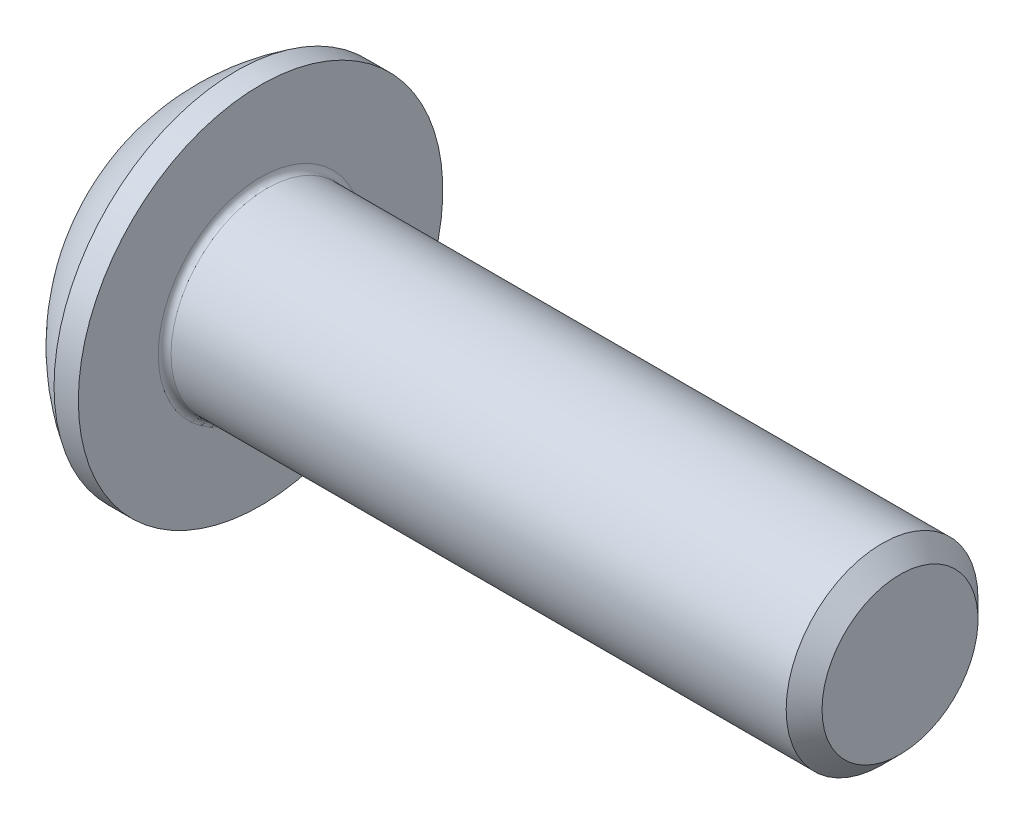
from build123d import *

# Parameters (mm, degrees)
FILLET1_R   = 0.1
HEX_2_DEPTH = 1.04


with BuildPart() as part:
    # BodySke → BaseBody (revolve)
    with BuildSketch(Plane.XY):
        with BuildLine():
            Line((11.65, 0), (11.65, 1.2195))
            Line((11.65, 1.2195), (11.3695, 1.5))
            Line((11.3695, 1.5), (1.65, 1.5))
            Line((1.65, 1.5), (1.65, 2.85))
            Line((1.65, 2.85), (1.27, 2.85))
            ThreePointArc((1.27, 2.85), (0.53140404, 2.229827628), (0, 1.425))
            Line((0, 1.425), (0, 0))
            Line((0, 0), (11.65, 0))
        make_face()
    revolve(axis=Axis((0, 0, 0), (1, 0, 0)))

    # Fillet1
    fillet1_edges = [part.edges().sort_by_distance(p)[0] for p in [
        (1.65, -1.5, 0),
    ]]
    fillet(fillet1_edges, radius=FILLET1_R)

    # Sketch2 → PreBroach (revolve, cut)
    with BuildSketch(Plane.XY):
        Polygon((0, 1), (1.04, 1), (1.617350269, 0), (0, 0), align=None)
    revolve(axis=Axis((0, 0, 0), (1, 0, 0)), mode=Mode.SUBTRACT)

    # Sketch3 → Hex 2 (cut)
    with BuildSketch(Plane(origin=(0, 0, 0), x_dir=(0, 0, -1), z_dir=(1, 0, 0))):
        Polygon((-1, -0.577350269), (-1, 0.577350269), (0, 1.154700538), (1, 0.577350269), (1, -0.577350269), (0, -1.154700538), align=None)
    extrude(amount=HEX_2_DEPTH, mode=Mode.SUBTRACT)


solid = part.part
